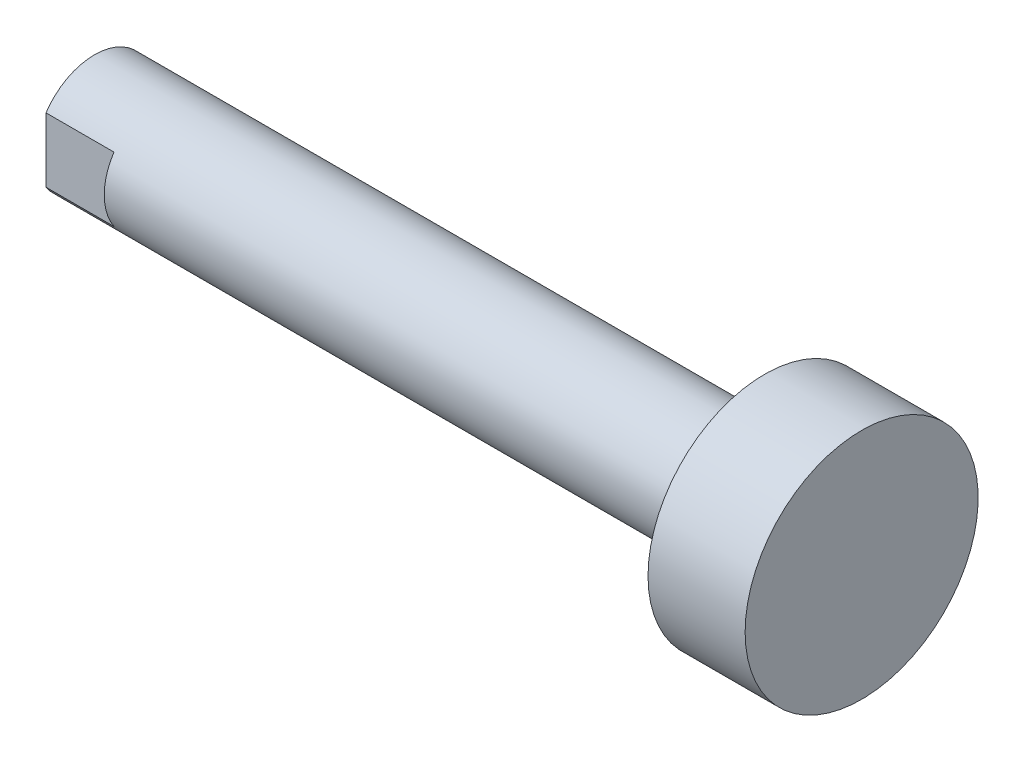
from build123d import *

# Parameters (mm, degrees)
SKETCH1_W                = 5
SKETCH1_H                = 6
SKETCH2_R                = 3
BOSS_EXTRUDE1_DEPTH      = 34.5
CUT_EXTRUDE1_DEPTH       = 3.5
CUT_EXTRUDE2_DEPTH       = 3.5
M2_CLEARANCE_HOLE1_D     = 2.459
M2_CLEARANCE_HOLE1_DEPTH = 6
M2_CLEARANCE_HOLE1_TIP   = 0.709852156
CHAMFER1_SIZE            = 0.2705


with BuildPart() as part:
    # Sketch1 → Revolve1 (revolve)
    with BuildSketch(Plane(origin=(0, 0, 0), x_dir=(-1, 0, 0), z_dir=(0, 0, -1))):
        with Locations((-33.5, 3)):
            Rectangle(SKETCH1_W, SKETCH1_H)
    revolve(axis=Axis((36, 0, 0), (-1, 0, 0)))

    # Sketch2 → Boss-Extrude1 (add)
    with BuildSketch(Plane.ZY.offset(-31)):
        Circle(SKETCH2_R)
    extrude(amount=BOSS_EXTRUDE1_DEPTH)

    # Sketch3 → Cut-Extrude1 (cut)
    with BuildSketch(Plane.ZY.offset(3.5)):
        with BuildLine():
            Line((-2.5, -1.658312395), (-2.5, 1.658312395))
            ThreePointArc((-2.5, 1.658312395), (-3, 0), (-2.5, -1.658312395))
        make_face()
    extrude(amount=-CUT_EXTRUDE1_DEPTH, mode=Mode.SUBTRACT)

    # Sketch4 → Cut-Extrude2 (cut)
    with BuildSketch(Plane.ZY.offset(3.5)):
        with BuildLine():
            Line((2.5, 1.658312395), (2.5, -1.658312395))
            ThreePointArc((2.5, -1.658312395), (3, 0), (2.5, 1.658312395))
        make_face()
    extrude(amount=-CUT_EXTRUDE2_DEPTH, mode=Mode.SUBTRACT)

    # M2 Clearance Hole1
    with Locations(Plane.ZY.offset(3.5)):
        with Locations((0, 0)):
            Hole(M2_CLEARANCE_HOLE1_D / 2, depth=M2_CLEARANCE_HOLE1_DEPTH)
            with Locations((0, 0, -(M2_CLEARANCE_HOLE1_DEPTH + M2_CLEARANCE_HOLE1_TIP / 2))):  # 120° drill point
                Cone(0, M2_CLEARANCE_HOLE1_D / 2, M2_CLEARANCE_HOLE1_TIP, mode=Mode.SUBTRACT)

    # Chamfer1
    chamfer1_edges = [part.edges().sort_by_distance(p)[0] for p in [
        (-3.5, 0, 1.2295),
    ]]
    chamfer(chamfer1_edges, length=CHAMFER1_SIZE)


solid = part.part
